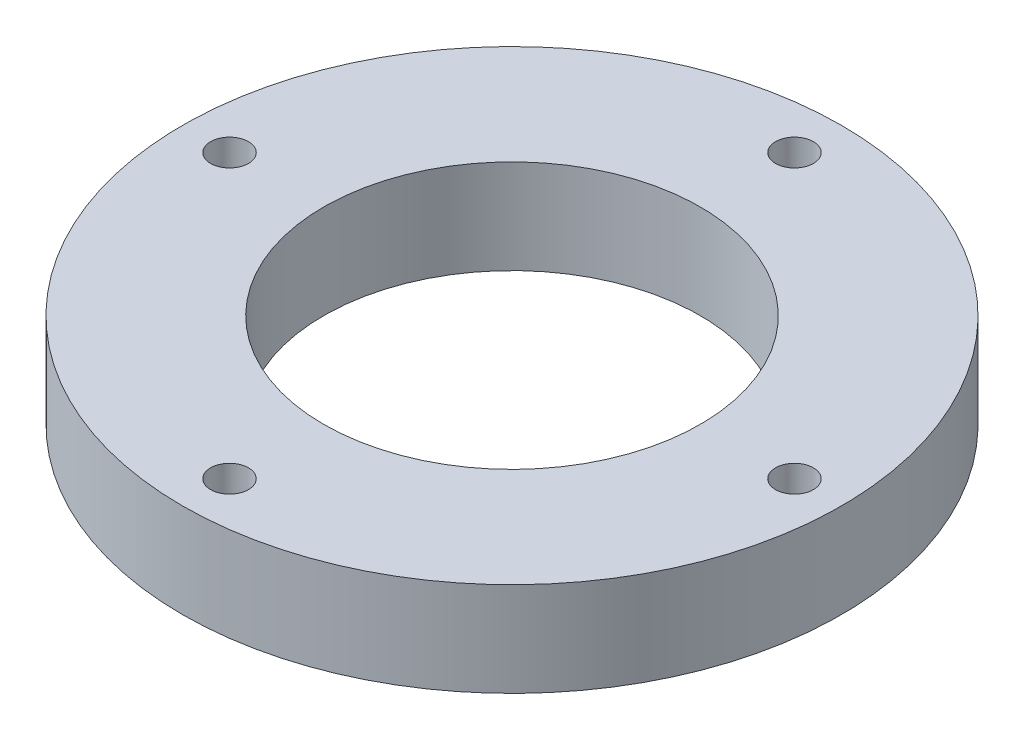
from build123d import *

# Parameters (mm, degrees)
SKETCH1_R                  = 44.45
BOSS_EXTRUDE1_DEPTH        = 12.7
SKETCH2_R                  = 25.4
CUT_EXTRUDE1_DEPTH         = 13.7
F_7_0_201_DIAMETER_HOLE1_D = 5.1054
CIRPATTERN1_COUNT          = 4


with BuildPart() as part:
    # Sketch1 → Boss-Extrude1 (new body)
    with BuildSketch(Plane(origin=(0, 0, 0), x_dir=(1, 0, 0), z_dir=(0, 1, 0))):
        with Locations(Location((0, 0, 0), (0, 0, 270))):  # turned: the seam where the file's is
            Circle(SKETCH1_R)
    extrude(amount=BOSS_EXTRUDE1_DEPTH)

    # Sketch2 → Cut-Extrude1 (cut, through all)
    with BuildSketch(Plane(origin=(0, 12.7, 0), x_dir=(1, 0, 0), z_dir=(0, 1, 0))):
        with Locations(Location((0, 0, 0), (0, 0, 270))):  # turned: the seam where the file's is
            Circle(SKETCH2_R)
    extrude(amount=-CUT_EXTRUDE1_DEPTH, mode=Mode.SUBTRACT)

    # #7 (0.201) Diameter Hole1 (through all)
    with Locations(Plane(origin=(0, 12.7, 0), x_dir=(-1, 0, 0), z_dir=(0, 1, 0))):
        with Locations((0, -38.1)):
            f_7_0_201_diameter_hole1 = Hole(F_7_0_201_DIAMETER_HOLE1_D / 2)

    # CirPattern1: #7 (0.201) Diameter Hole1 ×4 about axis
    cirpattern1_axis = Axis((0, 0, 0), (0, 1, 0))
    for i in range(1, CIRPATTERN1_COUNT):
        add(f_7_0_201_diameter_hole1.rotate(cirpattern1_axis, i * 360 / CIRPATTERN1_COUNT), mode=Mode.SUBTRACT)


solid = part.part
